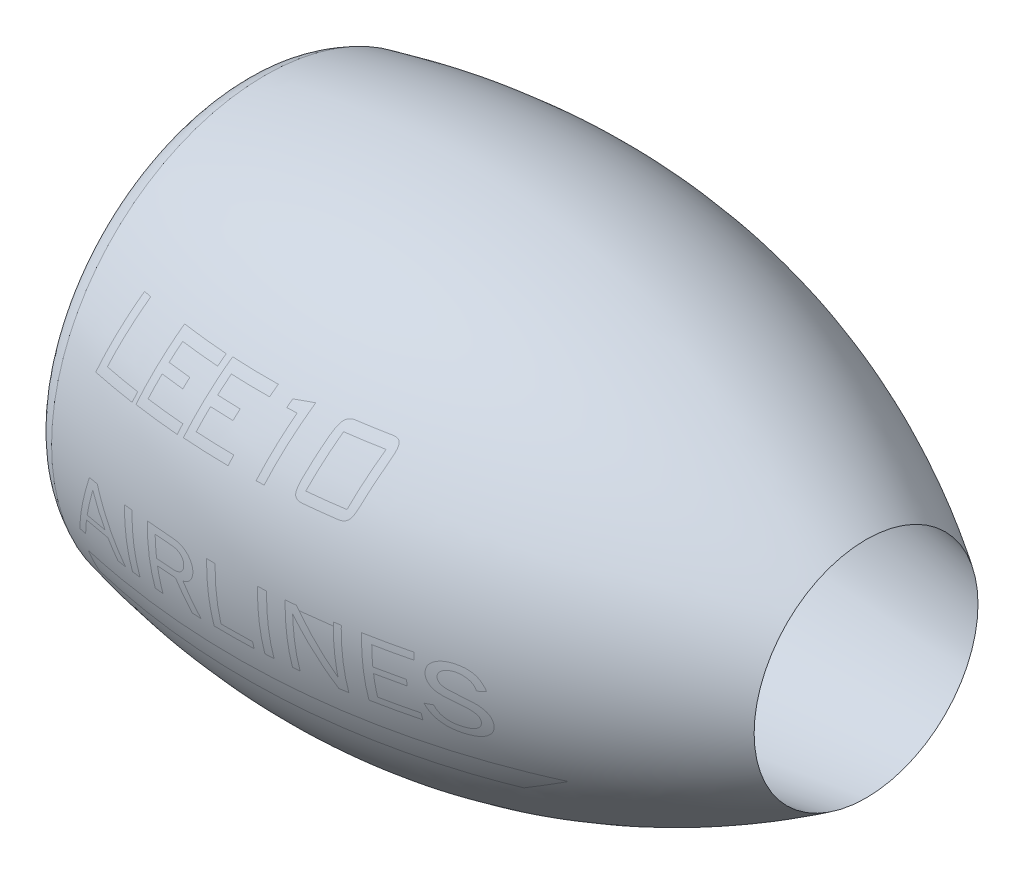
from build123d import *


with BuildPart() as part:
    # Sketch1 → Revolve1 (revolve)
    with BuildSketch(Plane.XY):
        with BuildLine():
            Line((0, 180), (25, 180))
            Line((25, 180), (35.278359264, 190))
            Line((35.278359264, 190), (86.973514106, 190))
            Line((86.973514106, 190), (580, 108))
            add(Edge.make_bspline(
                [(0, 205.84687817), (312.94999618, 281.232967471), (580, 108)],
                knots=[0, 0, 0, 1, 1, 1], degree=2))
            add(Edge.make_bspline(
                [(0, 205.84687817), (-35.175128005, 189.095377588), (0, 180)],
                knots=[0, 0, 0, 1, 1, 1], degree=2))
        make_face()
    revolve(axis=Axis((0, 0, 0), (1, 0, 0)))


solid = part.part
